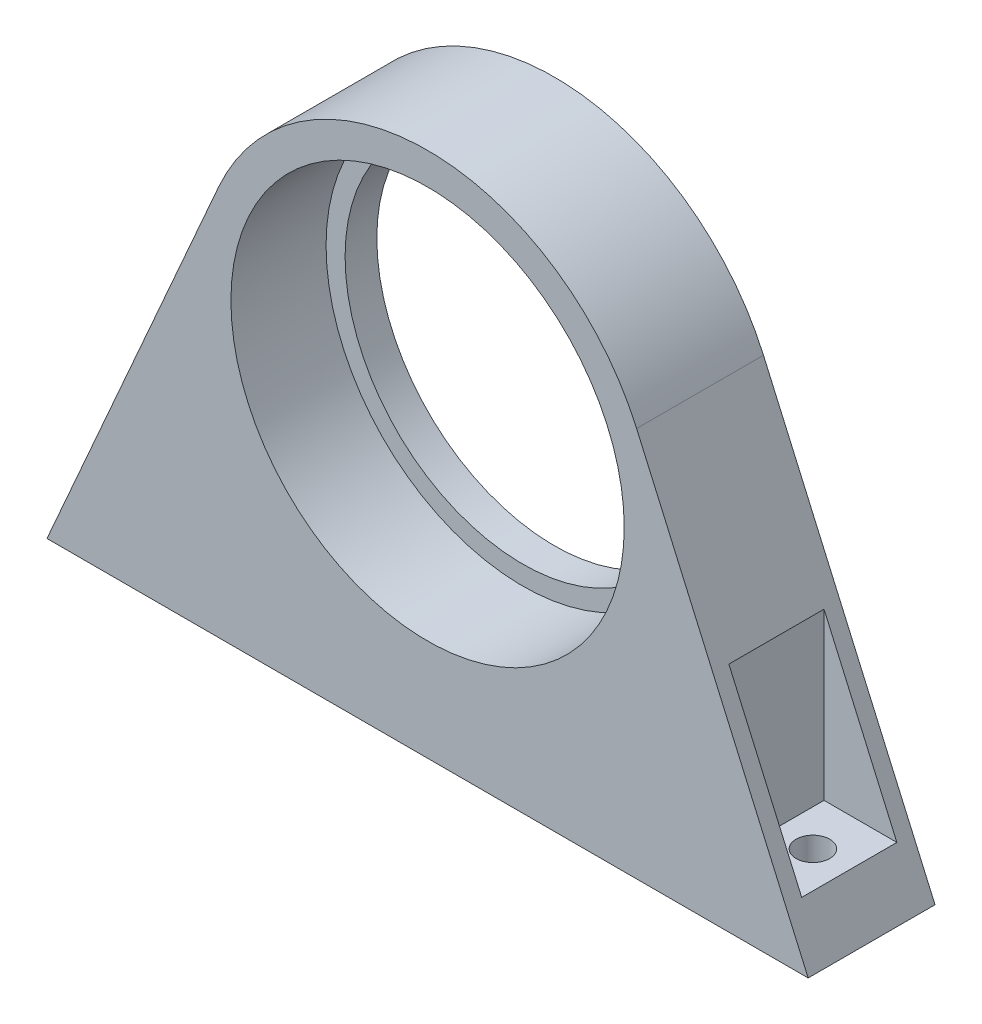
from build123d import *

# Parameters (mm, degrees)
SKETCH2_R           = 31
BOSS_EXTRUDE1_DEPTH = 20
SKETCH3_R           = 31
SKETCH3_R_2         = 28
BOSS_EXTRUDE2_DEPTH = 5
CUT_EXTRUDE1_START  = -8
SKETCH4_W           = 15
SKETCH4_H           = 15
CUT_EXTRUDE1_DEPTH  = 76
SKETCH5_R           = 2.65
CUT_EXTRUDE2_DEPTH  = 9


with BuildPart() as part:
    # Sketch2 → Boss-Extrude1 (new body)
    with BuildSketch(Plane.XY):
        with BuildLine():
            Line((-60, -47), (-32.953458565, 14.493776892))
            ThreePointArc((-32.953458565, 14.493776892), (0, 36), (32.953458565, 14.493776892))
            Line((32.953458565, 14.493776892), (60, -47))
            Line((60, -47), (-60, -47))
        make_face()
        Circle(SKETCH2_R, mode=Mode.SUBTRACT)
    extrude(amount=BOSS_EXTRUDE1_DEPTH)

    # Sketch3 → Boss-Extrude2 (add)
    with BuildSketch(Plane(origin=(0, 0, 0), x_dir=(-1, 0, 0), z_dir=(0, 0, -1))):
        Circle(SKETCH3_R)
        Circle(SKETCH3_R_2, mode=Mode.SUBTRACT)
    extrude(amount=-BOSS_EXTRUDE2_DEPTH)

    # Sketch4 → Cut-Extrude1 (cut, through all)
    with BuildSketch(Plane.XZ.offset(47).offset(CUT_EXTRUDE1_START)):
        with Locations((-52.5, 10)):
            Rectangle(SKETCH4_W, SKETCH4_H)
        with Locations((52.5, 10)):
            Rectangle(SKETCH4_W, SKETCH4_H)
    extrude(amount=-CUT_EXTRUDE1_DEPTH, mode=Mode.SUBTRACT)

    # Sketch5 → Cut-Extrude2 (cut, through all)
    with BuildSketch(Plane(origin=(0, -39, 0), x_dir=(1, 0, 0), z_dir=(0, 1, 0))):
        with Locations((-50.740697332, -10)):
            Circle(SKETCH5_R)
        with Locations((50.740697332, -10)):
            Circle(SKETCH5_R)
    extrude(amount=-CUT_EXTRUDE2_DEPTH, mode=Mode.SUBTRACT)


solid = part.part
